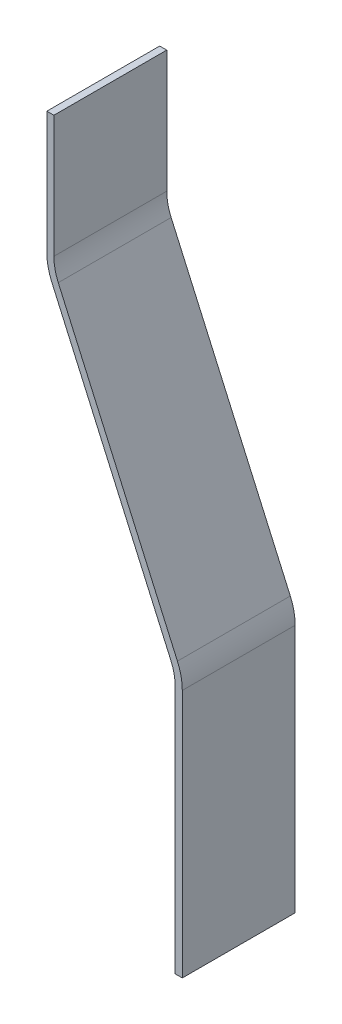
from build123d import *

# Parameters (mm, degrees)
BOSS_EXTRUDE1_DEPTH = 101.6


with BuildPart() as part:
    # Sketch1 → Boss-Extrude1 (new body)
    with BuildSketch(Plane.XY):
        with BuildLine():
            Line((60.96, 197.131308881), (60.96, 307.367308881))
            Line((60.96, 307.367308881), (67.31, 307.367308881))
            Line((67.31, 307.367308881), (67.31, 197.400739769))
            ThreePointArc((67.31, 197.400739769), (68.305399944, 187.9124022), (71.248256772, 178.837218205))
            Line((71.248256772, 178.837218205), (178.504159142, -62.568409333))
            ThreePointArc((178.504159142, -62.568409333), (181.774000062, -72.651947106), (182.88, -83.194544404))
            Line((182.88, -83.194544404), (182.88, -307.367308881))
            Line((182.88, -307.367308881), (176.53, -307.367308881))
            Line((176.53, -307.367308881), (176.53, -83.463975292))
            ThreePointArc((176.53, -83.463975292), (175.534600056, -73.975637723), (172.591743228, -64.900453728))
            Line((172.591743228, -64.900453728), (65.335840858, 176.50517381))
            ThreePointArc((65.335840858, 176.50517381), (62.065999938, 186.588711582), (60.96, 197.131308881))
        make_face()
    extrude(amount=BOSS_EXTRUDE1_DEPTH)


solid = part.part
